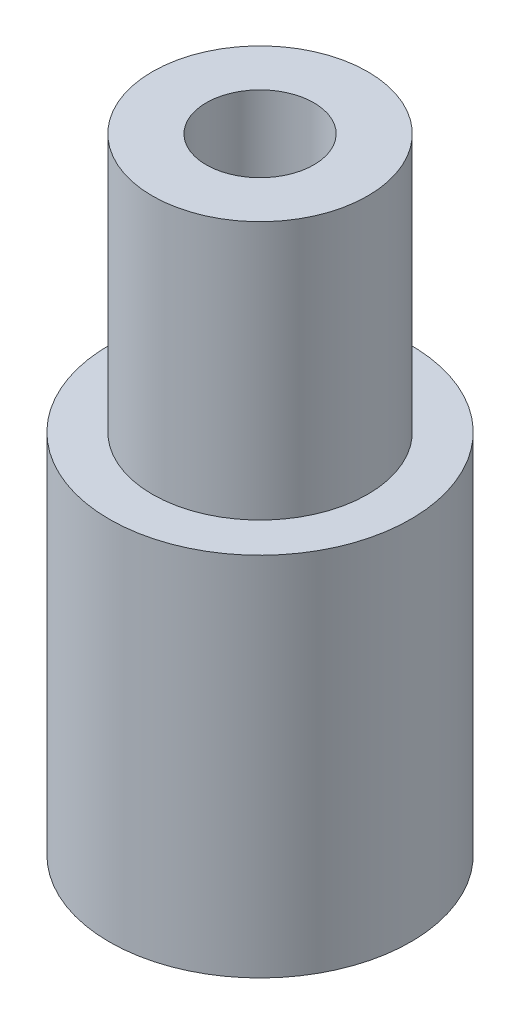
from build123d import *

# Parameters (mm, degrees)
SKETCH1_R           = 7
BOSS_EXTRUDE1_DEPTH = 17
SKETCH2_R           = 5
BOSS_EXTRUDE2_DEPTH = 12
SKETCH3_R           = 2.5
CUT_EXTRUDE1_DEPTH  = 14


with BuildPart() as part:
    # Sketch1 → Boss-Extrude1 (new body)
    with BuildSketch(Plane(origin=(0, 0, 0), x_dir=(1, 0, 0), z_dir=(0, 1, 0))):
        Circle(SKETCH1_R)
    extrude(amount=BOSS_EXTRUDE1_DEPTH)

    # Sketch2 → Boss-Extrude2 (add)
    with BuildSketch(Plane(origin=(0, 17, 0), x_dir=(1, 0, 0), z_dir=(0, 1, 0))):
        Circle(SKETCH2_R)
    extrude(amount=BOSS_EXTRUDE2_DEPTH)

    # Sketch3 → Cut-Extrude1 (cut)
    with BuildSketch(Plane(origin=(0, 29, 0), x_dir=(1, 0, 0), z_dir=(0, 1, 0))):
        Circle(SKETCH3_R)
    extrude(amount=-CUT_EXTRUDE1_DEPTH, mode=Mode.SUBTRACT)


solid = part.part
